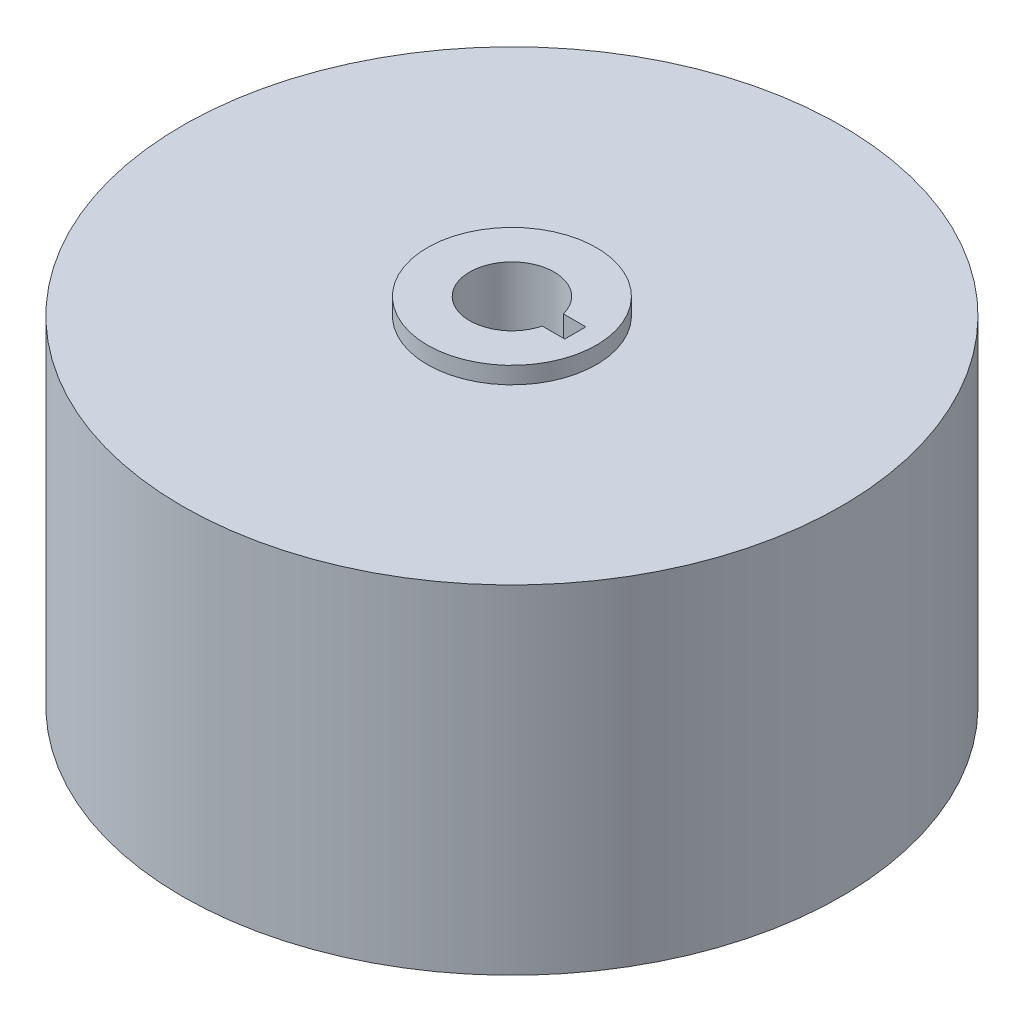
from build123d import *

# Parameters (mm, degrees)
SKETCH1_R                = 39
BOSS_EXTRUDE1_DEPTH      = 40
SKETCH2_R                = 10
BOSS_EXTRUDE2_DEPTH      = 2
BOSS_EXTRUDE2_DEPTH_BACK = 42
SKETCH3_R                = 5
CUT_EXTRUDE1_DEPTH       = 1
CUT_EXTRUDE1_DEPTH_BACK  = 45
SKETCH4_W                = 5
SKETCH4_H                = 2.5
CUT_EXTRUDE2_DEPTH       = 45


with BuildPart() as part:
    # Sketch1 → Boss-Extrude1 (new body)
    with BuildSketch(Plane(origin=(0, 0, 0), x_dir=(1, 0, 0), z_dir=(0, 1, 0))):
        Circle(SKETCH1_R)
    extrude(amount=BOSS_EXTRUDE1_DEPTH)

    # Sketch2 → Boss-Extrude2 (add, two sides)
    with BuildSketch(Plane(origin=(0, 40, 0), x_dir=(1, 0, 0), z_dir=(0, 1, 0))) as boss_extrude2_sk:
        Circle(SKETCH2_R)
    extrude(amount=BOSS_EXTRUDE2_DEPTH)
    extrude(boss_extrude2_sk.sketch, amount=-BOSS_EXTRUDE2_DEPTH_BACK)

    # Sketch3 → Cut-Extrude1 (cut, two sides)
    with BuildSketch(Plane(origin=(0, 42, 0), x_dir=(1, 0, 0), z_dir=(0, 1, 0))) as cut_extrude1_sk:
        Circle(SKETCH3_R)
    extrude(amount=CUT_EXTRUDE1_DEPTH, mode=Mode.SUBTRACT)
    extrude(cut_extrude1_sk.sketch, amount=-CUT_EXTRUDE1_DEPTH_BACK, mode=Mode.SUBTRACT)

    # Sketch4 → Cut-Extrude2 (cut, through all)
    with BuildSketch(Plane(origin=(0, 42, 0), x_dir=(1, 0, 0), z_dir=(0, 1, 0))):
        with Locations((5, 0)):
            Rectangle(SKETCH4_W, SKETCH4_H)
    extrude(amount=-CUT_EXTRUDE2_DEPTH, mode=Mode.SUBTRACT)


solid = part.part
